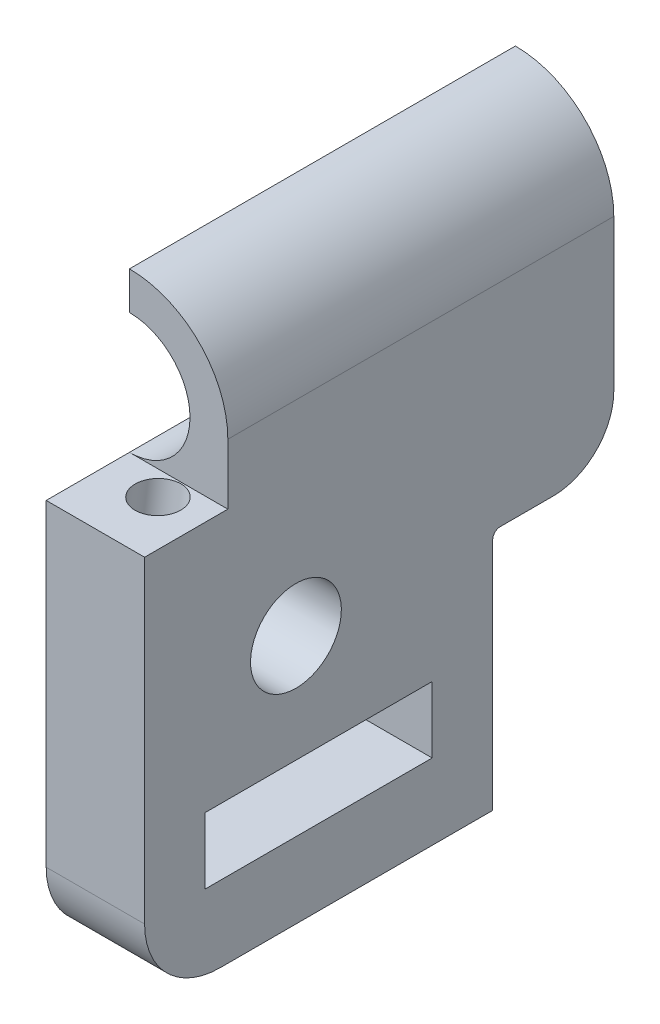
from build123d import *

# Parameters (mm, degrees)
BOSS_EXTRUDE1_DEPTH = 31
SKETCH2_W           = 5.5
SKETCH2_H           = 10.5
CUT_EXTRUDE1_DEPTH  = 7.5
SKETCH3_R           = 3
CUT_EXTRUDE2_DEPTH  = 7.5
CUT_EXTRUDE5_REACH  = 8.5
SKETCH6_W           = 8
SKETCH6_H           = 13
FILLET1_R           = 0.5
FILLET2_R           = 4
CUT_EXTRUDE7_REACH  = 27.5
SKETCH9_R           = 1.5
CUT_EXTRUDE8_DEPTH  = 17
CUT_EXTRUDE9_DEPTH  = 10
FILLET3_R           = 5
SKETCH11_W          = 15
SKETCH11_H          = 4.374689329
CUT_EXTRUDE10_DEPTH = 7.5


with BuildPart() as part:
    # Sketch1 → Boss-Extrude1 (new body)
    with BuildSketch(Plane.XY):
        with BuildLine():
            Line((-3.75, 29), (-3.75, 22.5))
            Line((-3.75, 22.5), (-3.75, -22.5))
            Line((-3.75, -22.5), (2.75, -22.5))
            Line((2.75, -22.5), (2.75, 22.5))
            ThreePointArc((2.75, 22.5), (0.846194078, 27.096194078), (-3.75, 29))
        make_face()
    extrude(amount=BOSS_EXTRUDE1_DEPTH)

    # Sketch2 → Cut-Extrude1 (cut, through all)
    with BuildSketch(Plane.ZY.offset(3.75)):
        with Locations((28.25, 23.75)):
            Rectangle(SKETCH2_W, SKETCH2_H)
    extrude(amount=-CUT_EXTRUDE1_DEPTH, mode=Mode.SUBTRACT)

    # Sketch3 → Cut-Extrude2 (cut, through all)
    with BuildSketch(Plane.ZY.offset(3.75)):
        with Locations((21, 9)):
            Circle(SKETCH3_R)
        with Locations((21, -12.5)):
            Circle(SKETCH3_R)
    extrude(amount=-CUT_EXTRUDE2_DEPTH, mode=Mode.SUBTRACT)

    # Sketch6 → Cut-Extrude5 (cut, up to next)
    with BuildSketch(Plane.ZY.offset(3.75), mode=Mode.PRIVATE) as cut_extrude5_sk1:
        with Locations((4, 2)):
            Rectangle(SKETCH6_W, SKETCH6_H)
    cut_extrude5_tool1 = extrude(cut_extrude5_sk1.sketch, amount=-CUT_EXTRUDE5_REACH, mode=Mode.PRIVATE) & part.part
    add(cut_extrude5_tool1.solids().sort_by_distance((-3.75, 2, 4))[0], mode=Mode.SUBTRACT)

    # Fillet1
    fillet1_edges = [part.edges().sort_by_distance(p)[0] for p in [
        (-0.5, 8.5, 8),
        (-0.5, -4.5, 8),
    ]]
    fillet(fillet1_edges, radius=FILLET1_R)

    # Fillet2
    fillet2_edges = [part.edges().sort_by_distance(p)[0] for p in [
        (-0.5, -4.5, 0),
        (-0.5, 8.5, 0),
    ]]
    fillet(fillet2_edges, radius=FILLET2_R)

    # Sketch8 → Cut-Extrude7 (cut, up to next)
    with BuildSketch(Plane.XY.offset(25.5), mode=Mode.PRIVATE) as cut_extrude7_sk1:
        with BuildLine():
            Line((-3.75, 26.5), (-3.75, 18.5))
            ThreePointArc((-3.75, 18.5), (0.25, 22.5), (-3.75, 26.5))
        make_face()
    cut_extrude7_tool1 = extrude(cut_extrude7_sk1.sketch, amount=-CUT_EXTRUDE7_REACH, mode=Mode.PRIVATE) & part.part
    add(cut_extrude7_tool1.solids().sort_by_distance((-2.052347, 22.5, 25.5))[0], mode=Mode.SUBTRACT)

    # Sketch9 → Cut-Extrude8 (cut)
    with BuildSketch(Plane(origin=(0, 14.627294401, -2.055732165), x_dir=(-1, 0, 0), z_dir=(0, 0.990268069, -0.139173101))):
        with Locations((0.25, 29.426538121)):
            Circle(SKETCH9_R)
    extrude(amount=-CUT_EXTRUDE8_DEPTH, mode=Mode.SUBTRACT)

    # Sketch10 → Cut-Extrude9 (cut)
    with BuildSketch(Plane.ZY.offset(3.75)):
        Polygon((8, -7.48664609), (35.202378245, -7.48664609), (35.202378245, -24.00834186), (-1.764970627, -24.00834186), (-1.764970627, -2.884142505), (8, -2.884142505), align=None)
    extrude(amount=-CUT_EXTRUDE9_DEPTH, mode=Mode.SUBTRACT)

    # Fillet3
    fillet3_edges = [part.edges().sort_by_distance(p)[0] for p in [
        (-0.5, -7.48664609, 31),
    ]]
    fillet(fillet3_edges, radius=FILLET3_R)

    # Sketch11 → Cut-Extrude10 (cut, through all)
    with BuildSketch(Plane.ZY.offset(3.75)):
        with Locations((19.5, -0.299301426)):
            Rectangle(SKETCH11_W, SKETCH11_H)
    extrude(amount=-CUT_EXTRUDE10_DEPTH, mode=Mode.SUBTRACT)


solid = part.part
